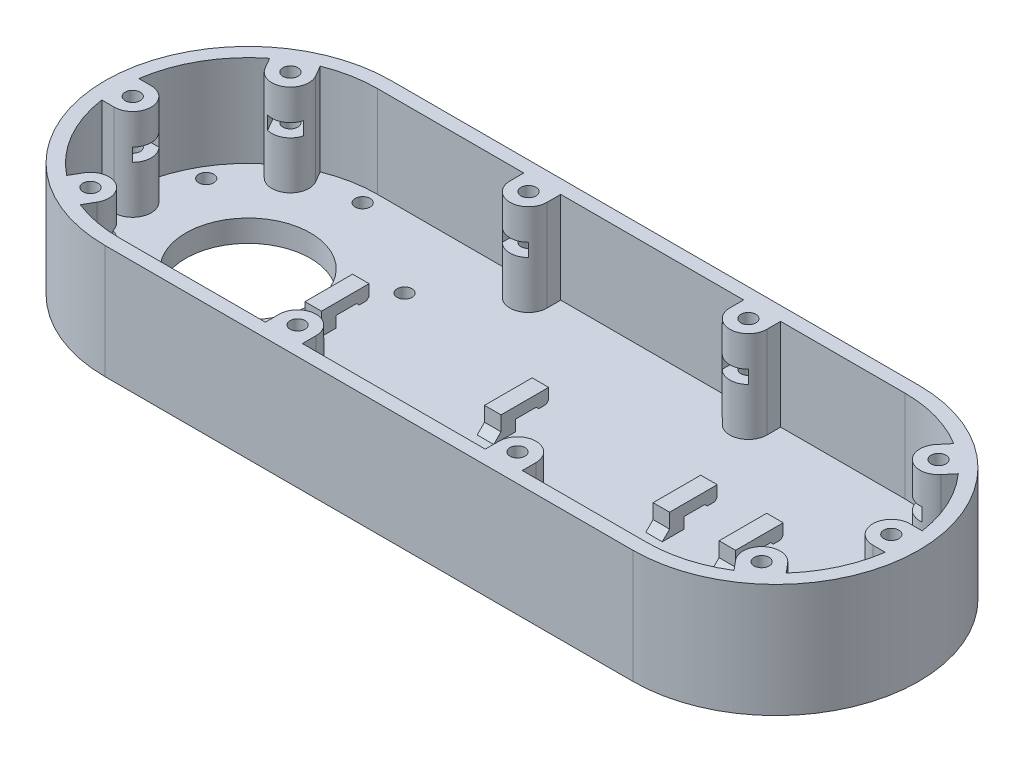
from build123d import *

# Parameters (mm, degrees)
BOSS_EXTRUDE1_DEPTH             = 6
BOSS_EXTRUDE2_DEPTH             = 25
SKETCH3_R                       = 17
SKETCH3_R_2                     = 2.05
CUT_EXTRUDE1_DEPTH              = 189.77234967
SKETCH4_R                       = 2.05
BOSS_EXTRUDE3_DEPTH             = 25
CUT_EXTRUDE2_DEPTH              = 3.6
CIRPATTERN2_COUNT               = 2
CIRPATTERN2_ANGLE               = 60
CIRPATTERN2_THE_OTHER_WAY_COUNT = 2
CIRPATTERN2_THE_OTHER_WAY_ANGLE = 60
SKETCH6_R                       = 2.05
BOSS_EXTRUDE4_DEPTH             = 25
CUT_EXTRUDE3_DEPTH              = 3.6
CIRPATTERN3_COUNT               = 2
CIRPATTERN3_ANGLE               = 50
CIRPATTERN3_THE_OTHER_WAY_COUNT = 2
CIRPATTERN3_THE_OTHER_WAY_ANGLE = 50
SKETCH8_R                       = 2.05
BOSS_EXTRUDE5_DEPTH             = 25
CUT_EXTRUDE4_DEPTH              = 3.6
LPATTERN1_COUNT                 = 2
LPATTERN1_PITCH                 = 60
MIRROR2_COPY_1_SKETCH_R         = 2.05
MIRROR2_COPY_1_DEPTH            = 25
MIRROR2_COPY_2_DEPTH            = 3.6
BOSS_EXTRUDE6_DEPTH             = 4.5
LPATTERN2_COUNT                 = 2
LPATTERN2_PITCH                 = 18
LPATTERN3_COUNT                 = 2
LPATTERN3_PITCH                 = 64
LPATTERN4_COUNT                 = 2
LPATTERN4_PITCH                 = 113
CHAMFER1_SIZE                   = 2


with BuildPart() as part:
    # Sketch1 → Boss-Extrude1 (new body)
    with BuildSketch(Plane(origin=(0, 0, 0), x_dir=(1, 0, 0), z_dir=(0, 1, 0))):
        with BuildLine():
            Line((-144, 39), (0, 39))
            ThreePointArc((0, 39), (39, 0), (0, -39))
            Line((0, -39), (-144, -39))
            ThreePointArc((-144, -39), (-183, 0), (-144, 39))
        make_face()
    extrude(amount=BOSS_EXTRUDE1_DEPTH)

    # Sketch2 → Boss-Extrude2 (add)
    with BuildSketch(Plane(origin=(0, 6, 0), x_dir=(1, 0, 0), z_dir=(0, 1, 0))):
        with BuildLine():
            Line((-144, -39), (0, -39))
            ThreePointArc((0, -39), (39, 0), (0, 39))
            Line((0, 39), (-144, 39))
            ThreePointArc((-144, 39), (-183, 0), (-144, -39))
        make_face()
        with BuildLine():
            Line((-144, -35.25), (0, -35.25))
            ThreePointArc((0, -35.25), (35.25, 0), (0, 35.25))
            Line((0, 35.25), (-144, 35.25))
            ThreePointArc((-144, 35.25), (-179.25, 0), (-144, -35.25))
        make_face(mode=Mode.SUBTRACT)
    extrude(amount=BOSS_EXTRUDE2_DEPTH)

    # Sketch3 → Cut-Extrude1 (cut, through all)
    with BuildSketch(Plane(origin=(0, 6, 0), x_dir=(1, 0, 0), z_dir=(0, 1, 0))):
        with Locations(Location((-144, 0, 0), (0, 0, 270))):
            Circle(SKETCH3_R)
        with Locations(Location((-144, 31.25, 0), (0, 0, 270))):
            Circle(SKETCH3_R_2)
        with Locations(Location((-116.936706132, 15.625, 0), (0, 0, 270))):
            Circle(SKETCH3_R_2)
        with Locations(Location((-116.936706132, -15.625, 0), (0, 0, 270))):
            Circle(SKETCH3_R_2)
        with Locations(Location((-144, -31.25, 0), (0, 0, 270))):
            Circle(SKETCH3_R_2)
        with Locations(Location((-171.063293868, -15.625, 0), (0, 0, 270))):
            Circle(SKETCH3_R_2)
        with Locations(Location((-171.063293868, 15.625, 0), (0, 0, 270))):
            Circle(SKETCH3_R_2)
    extrude(amount=-CUT_EXTRUDE1_DEPTH, mode=Mode.SUBTRACT)

    # Sketch4 → Boss-Extrude3 (add)
    with BuildSketch(Plane(origin=(0, 6, 0), x_dir=(1, 0, 0), z_dir=(0, 1, 0))):
        with BuildLine():
            Line((-175.5, 5.05), (-178.88638703, 5.05))
            ThreePointArc((-178.88638703, 5.05), (-179.25, 0), (-178.88638703, -5.05))
            Line((-178.88638703, -5.05), (-175.5, -5.05))
            ThreePointArc((-175.5, -5.05), (-170.45, 0), (-175.5, 5.05))
        make_face()
        with Locations(Location((-175.5, 0, 0), (0, 0, 270))):
            Circle(SKETCH4_R, mode=Mode.SUBTRACT)
    boss_extrude3 = extrude(amount=BOSS_EXTRUDE3_DEPTH)

    # Sketch5 → Cut-Extrude2 (cut)
    with BuildSketch(Plane(origin=(0, 19, 0), x_dir=(1, 0, 0), z_dir=(0, 1, 0))):
        with BuildLine():
            Line((-171.958460787, 3.6), (-177.578460969, 3.6))
            Line((-177.578460969, 3.6), (-179.656921938, 0))
            Line((-179.656921938, 0), (-177.578460969, -3.6))
            Line((-177.578460969, -3.6), (-171.958460787, -3.6))
            ThreePointArc((-171.958460787, -3.6), (-170.45, 0), (-171.958460787, 3.6))
        make_face()
    cut_extrude2 = extrude(amount=CUT_EXTRUDE2_DEPTH, mode=Mode.SUBTRACT)

    # CirPattern2: Boss-Extrude3, Cut-Extrude2 ×2 about axis
    cirpattern2_axis = Axis((-144, 0, 0), (0, 1, 0))
    add([boss_extrude3.rotate(cirpattern2_axis, i * CIRPATTERN2_ANGLE / (CIRPATTERN2_COUNT - 1)) for i in range(1, CIRPATTERN2_COUNT)])
    add([cut_extrude2.rotate(cirpattern2_axis, i * CIRPATTERN2_ANGLE / (CIRPATTERN2_COUNT - 1)) for i in range(1, CIRPATTERN2_COUNT)], mode=Mode.SUBTRACT)

    # CirPattern2 the other way: Boss-Extrude3, Cut-Extrude2 ×2 about axis
    cirpattern2_the_other_way_axis = Axis((-144, 0, 0), (0, -1, 0))
    add([boss_extrude3.rotate(cirpattern2_the_other_way_axis, i * CIRPATTERN2_THE_OTHER_WAY_ANGLE / (CIRPATTERN2_THE_OTHER_WAY_COUNT - 1)) for i in range(1, CIRPATTERN2_THE_OTHER_WAY_COUNT)])
    add([cut_extrude2.rotate(cirpattern2_the_other_way_axis, i * CIRPATTERN2_THE_OTHER_WAY_ANGLE / (CIRPATTERN2_THE_OTHER_WAY_COUNT - 1)) for i in range(1, CIRPATTERN2_THE_OTHER_WAY_COUNT)], mode=Mode.SUBTRACT)

    # Sketch6 → Boss-Extrude4 (add)
    with BuildSketch(Plane(origin=(0, 6, 0), x_dir=(1, 0, 0), z_dir=(0, 1, 0))):
        with BuildLine():
            Line((34.88638703, 5.05), (31.5, 5.05))
            ThreePointArc((31.5, 5.05), (26.45, 0), (31.5, -5.05))
            Line((31.5, -5.05), (34.88638703, -5.05))
            ThreePointArc((34.88638703, -5.05), (35.25, 0), (34.88638703, 5.05))
        make_face()
        with Locations(Location((31.5, 0, 0), (0, 0, 270))):
            Circle(SKETCH6_R, mode=Mode.SUBTRACT)
    boss_extrude4 = extrude(amount=BOSS_EXTRUDE4_DEPTH)

    # Sketch7 → Cut-Extrude3 (cut)
    with BuildSketch(Plane(origin=(0, 19, 0), x_dir=(1, 0, 0), z_dir=(0, 1, 0))):
        with BuildLine():
            Line((33.578460969, 3.6), (27.958460787, 3.6))
            ThreePointArc((27.958460787, 3.6), (26.45, 0), (27.958460787, -3.6))
            Line((27.958460787, -3.6), (33.578460969, -3.6))
            Line((33.578460969, -3.6), (35.656921938, 0))
            Line((35.656921938, 0), (33.578460969, 3.6))
        make_face()
    cut_extrude3 = extrude(amount=CUT_EXTRUDE3_DEPTH, mode=Mode.SUBTRACT)

    # CirPattern3: Boss-Extrude4, Cut-Extrude3 ×2 about axis
    cirpattern3_axis = Axis((0, 0, 0), (0, -1, 0))
    add([boss_extrude4.rotate(cirpattern3_axis, i * CIRPATTERN3_ANGLE / (CIRPATTERN3_COUNT - 1)) for i in range(1, CIRPATTERN3_COUNT)])
    add([cut_extrude3.rotate(cirpattern3_axis, i * CIRPATTERN3_ANGLE / (CIRPATTERN3_COUNT - 1)) for i in range(1, CIRPATTERN3_COUNT)], mode=Mode.SUBTRACT)

    # CirPattern3 the other way: Boss-Extrude4, Cut-Extrude3 ×2 about axis
    cirpattern3_the_other_way_axis = Axis((0, 0, 0), (0, 1, 0))
    add([boss_extrude4.rotate(cirpattern3_the_other_way_axis, i * CIRPATTERN3_THE_OTHER_WAY_ANGLE / (CIRPATTERN3_THE_OTHER_WAY_COUNT - 1)) for i in range(1, CIRPATTERN3_THE_OTHER_WAY_COUNT)])
    add([cut_extrude3.rotate(cirpattern3_the_other_way_axis, i * CIRPATTERN3_THE_OTHER_WAY_ANGLE / (CIRPATTERN3_THE_OTHER_WAY_COUNT - 1)) for i in range(1, CIRPATTERN3_THE_OTHER_WAY_COUNT)], mode=Mode.SUBTRACT)

    # Sketch8 → Boss-Extrude5 (add)
    with BuildSketch(Plane(origin=(0, 6, 0), x_dir=(1, 0, 0), z_dir=(0, 1, 0))):
        with BuildLine():
            Line((-93.95, 31.5), (-93.95, 35.25))
            Line((-93.95, 35.25), (-104.05, 35.25))
            Line((-104.05, 35.25), (-104.05, 31.5))
            ThreePointArc((-104.05, 31.5), (-99, 26.45), (-93.95, 31.5))
        make_face()
        with Locations(Location((-99, 31.5, 0), (0, 0, 270))):
            Circle(SKETCH8_R, mode=Mode.SUBTRACT)
    boss_extrude5 = extrude(amount=BOSS_EXTRUDE5_DEPTH)

    # Sketch9 → Cut-Extrude4 (cut)
    with BuildSketch(Plane(origin=(0, 19, 0), x_dir=(1, 0, 0), z_dir=(0, 1, 0))):
        with BuildLine():
            Line((-95.4, 33.578460969), (-99, 35.656921938))
            Line((-99, 35.656921938), (-102.6, 33.578460969))
            Line((-102.6, 33.578460969), (-102.6, 27.958460787))
            ThreePointArc((-102.6, 27.958460787), (-99, 26.45), (-95.4, 27.958460787))
            Line((-95.4, 27.958460787), (-95.4, 33.578460969))
        make_face()
    cut_extrude4 = extrude(amount=CUT_EXTRUDE4_DEPTH, mode=Mode.SUBTRACT)

    # LPattern1: Boss-Extrude5, Cut-Extrude4 ×2
    with Locations(*[(i * LPATTERN1_PITCH, 0, 0) for i in range(1, LPATTERN1_COUNT)]):
        add(boss_extrude5)
        add(cut_extrude4, mode=Mode.SUBTRACT)

    # Mirror2: Boss-Extrude5, Cut-Extrude4 across plane
    add(boss_extrude5.mirror(Plane.XY))
    add(cut_extrude4.mirror(Plane.XY), mode=Mode.SUBTRACT)

    # Mirror2 copy 1 sketch → Mirror2 copy 1 (add)
    with BuildSketch(Plane(origin=(60, 6, 0), x_dir=(1, 0, 0), z_dir=(0, 1, 0))):
        with BuildLine():
            Line((-93.95, -31.5), (-93.95, -35.25))
            Line((-93.95, -35.25), (-104.05, -35.25))
            Line((-104.05, -35.25), (-104.05, -31.5))
            ThreePointArc((-104.05, -31.5), (-99, -26.45), (-93.95, -31.5))
        make_face()
        with Locations((-99, -31.5)):
            Circle(MIRROR2_COPY_1_SKETCH_R, mode=Mode.SUBTRACT)
    extrude(amount=MIRROR2_COPY_1_DEPTH)

    # Mirror2 copy 2 sketch → Mirror2 copy 2 (cut)
    with BuildSketch(Plane(origin=(60, 19, 0), x_dir=(1, 0, 0), z_dir=(0, 1, 0))):
        with BuildLine():
            Line((-95.4, -33.578460969), (-99, -35.656921938))
            Line((-99, -35.656921938), (-102.6, -33.578460969))
            Line((-102.6, -33.578460969), (-102.6, -27.958460787))
            ThreePointArc((-102.6, -27.958460787), (-99, -26.45), (-95.4, -27.958460787))
            Line((-95.4, -27.958460787), (-95.4, -33.578460969))
        make_face()
    extrude(amount=MIRROR2_COPY_2_DEPTH, mode=Mode.SUBTRACT)

    # Sketch10 → Boss-Extrude6 (add)
    with BuildSketch(Plane(origin=(-5, 0, 0), x_dir=(0, 0, -1), z_dir=(1, 0, 0))):
        Polygon((-2, 6), (-2, 9), (3.604928108, 9), (4.302464054, 8.302464054), (6.302464054, 8.302464054), (7, 9), (7, 12), (-6, 12), (-6, 6), align=None)
    boss_extrude6 = extrude(amount=-BOSS_EXTRUDE6_DEPTH)

    # LPattern2: Boss-Extrude6 ×2
    with Locations(*[(-i * LPATTERN2_PITCH, 0, 0) for i in range(1, LPATTERN2_COUNT)]):
        add(boss_extrude6)

    # LPattern3: Boss-Extrude6 ×2
    with Locations(*[(-i * LPATTERN3_PITCH, 0, 0) for i in range(1, LPATTERN3_COUNT)]):
        add(boss_extrude6)

    # LPattern4: Boss-Extrude6 ×2
    with Locations(*[(-i * LPATTERN4_PITCH, 0, 0) for i in range(1, LPATTERN4_COUNT)]):
        add(boss_extrude6)

    # Chamfer1
    chamfer1_edges = [part.edges().sort_by_distance(p)[0] for p in [
        (-7.25, 6, 6),
        (-25.25, 6, 6),
        (-71.25, 6, 6),
        (-120.25, 6, 6),
    ]]
    chamfer(chamfer1_edges, length=CHAMFER1_SIZE)


solid = part.part
